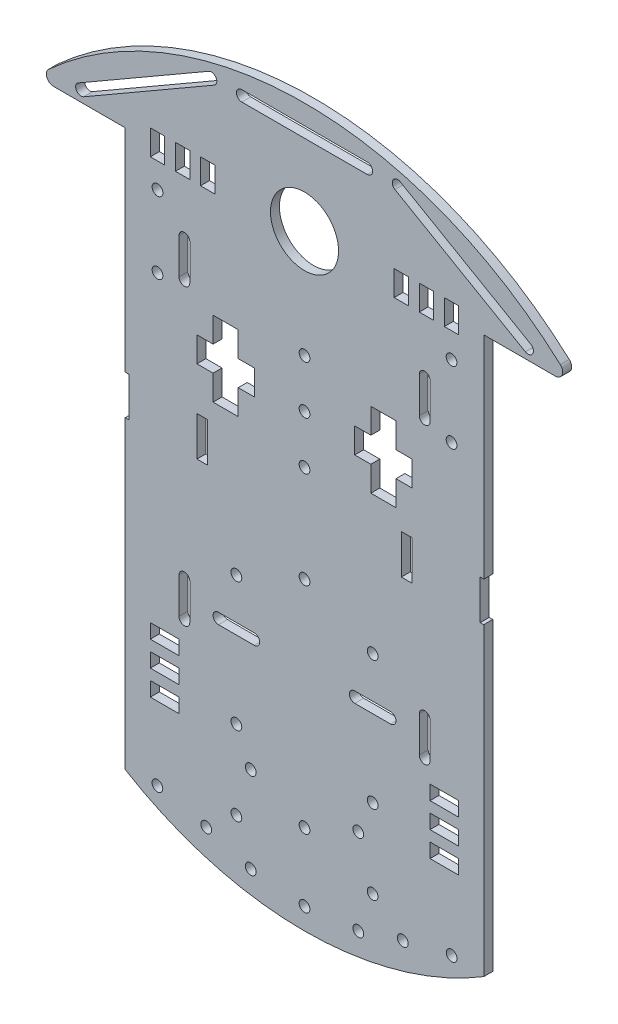
from build123d import *

# Parameters (mm, degrees)
BOSS_EXTRU_1_DEPTH         = 2.5
ESQUISSE2_R                = 9.5
ENL_V_MAT_EXTRU_1_DEPTH    = 3.5
ESQUISSE3_W                = 4
ESQUISSE3_H                = 7
ENL_V_MAT_EXTRU_2_DEPTH    = 3.5
R_P_TITION_LIN_AIRE1_COUNT = 3
R_P_TITION_LIN_AIRE1_PITCH = 7
ENL_V_MAT_EXTRU_3_DEPTH    = 3.5
ESQUISSE5_W                = 3
ESQUISSE5_H                = 11
ENL_V_MAT_EXTRU_4_DEPTH    = 3.5
R_P_TITION_LIN_AIRE2_COUNT = 2
R_P_TITION_LIN_AIRE2_PITCH = 22
ESQUISSE6_R                = 1.5
ENL_V_MAT_EXTRU_5_DEPTH    = 3.5
ESQUISSE7_W                = 8
ESQUISSE7_H                = 4
ENL_V_MAT_EXTRU_6_DEPTH    = 3.5
SYM_TRIE1_COPY_1_SKETCH_W  = 3
SYM_TRIE1_COPY_1_SKETCH_H  = 11
SYM_TRIE1_COPY_1_DEPTH     = 3.5
SYM_TRIE1_COPY_2_SKETCH_W  = 4
SYM_TRIE1_COPY_2_SKETCH_H  = 7
SYM_TRIE1_COPY_2_DEPTH     = 3.5
SYM_TRIE1_COPY_3_SKETCH_W  = 4
SYM_TRIE1_COPY_3_SKETCH_H  = 7
SYM_TRIE1_COPY_3_DEPTH     = 3.5
ESQUISSE8_R                = 1.5
ENL_V_MAT_EXTRU_7_DEPTH    = 10


with BuildPart() as part:
    # Esquisse1 → Boss.-Extru.1 (new body)
    with BuildSketch(Plane.XY):
        with BuildLine():
            Line((100, 155), (119.994239394, 155))
            ThreePointArc((119.994239394, 155), (121.860222821, 156.2802043), (121.337366241, 158.48189415))
            ThreePointArc((121.337366241, 158.48189415), (50, 186), (-21.337366241, 158.48189415))
            ThreePointArc((-21.337366241, 158.48189415), (-21.860222821, 156.2802043), (-19.994239394, 155))
            Line((-19.994239394, 155), (0, 155))
            Line((0, 155), (0, 0))
            ThreePointArc((0, 0), (50, -14), (100, 0))
            Line((100, 0), (100, 155))
        make_face()
    extrude(amount=BOSS_EXTRU_1_DEPTH)

    # Esquisse2 → Enlèv. mat.-Extru.1 (cut, through all)
    with BuildSketch(Plane(origin=(0, 0, 0), x_dir=(-1, 0, 0), z_dir=(0, 0, -1))):
        with Locations((-50, 155)):
            Circle(ESQUISSE2_R)
    extrude(amount=-ENL_V_MAT_EXTRU_1_DEPTH, mode=Mode.SUBTRACT)

    # Esquisse3 → Enlèv. mat.-Extru.2 (cut, through all)
    with BuildSketch(Plane(origin=(0, 0, 0), x_dir=(-1, 0, 0), z_dir=(0, 0, -1))):
        with Locations((-91, 155)):
            Rectangle(ESQUISSE3_W, ESQUISSE3_H)
    enl_v_mat_extru_2 = extrude(amount=-ENL_V_MAT_EXTRU_2_DEPTH, mode=Mode.SUBTRACT)

    # Répétition linéaire1: Enlèv. mat.-Extru.2 ×3
    with Locations(*[(-i * R_P_TITION_LIN_AIRE1_PITCH, 0, 0) for i in range(1, R_P_TITION_LIN_AIRE1_COUNT)]):
        add(enl_v_mat_extru_2, mode=Mode.SUBTRACT)

    # Esquisse4 → Enlèv. mat.-Extru.3 (cut, through all)
    with BuildSketch(Plane(origin=(0, 0, 0), x_dir=(-1, 0, 0), z_dir=(0, 0, -1))):
        Polygon((-75.5, 122), (-68.5, 122), (-68.5, 115), (-64, 115), (-64, 108), (-68.5, 108), (-68.5, 101), (-75.5, 101), (-75.5, 108), (-80, 108), (-80, 115), (-75.5, 115), align=None)
    enl_v_mat_extru_3 = extrude(amount=-ENL_V_MAT_EXTRU_3_DEPTH, mode=Mode.SUBTRACT)

    # Esquisse5 → Enlèv. mat.-Extru.4 (cut, through all)
    with BuildSketch(Plane(origin=(0, 0, 0), x_dir=(-1, 0, 0), z_dir=(0, 0, -1))):
        with Locations((-78.5, 90.5)):
            Rectangle(ESQUISSE5_W, ESQUISSE5_H)
    enl_v_mat_extru_4 = extrude(amount=-ENL_V_MAT_EXTRU_4_DEPTH, mode=Mode.SUBTRACT)

    # Répétition linéaire2: Enlèv. mat.-Extru.4 ×2
    with Locations(*[(i * R_P_TITION_LIN_AIRE2_PITCH, 0, 0) for i in range(1, R_P_TITION_LIN_AIRE2_COUNT)]):
        add(enl_v_mat_extru_4, mode=Mode.SUBTRACT)

    # Esquisse6 → Enlèv. mat.-Extru.5 (cut, through all)
    with BuildSketch(Plane(origin=(0, 0, 0), x_dir=(-1, 0, 0), z_dir=(0, 0, -1))):
        with Locations((-91, 144.5)):
            Circle(ESQUISSE6_R)
        with Locations((-91, 124.5)):
            Circle(ESQUISSE6_R)
        with Locations((-65, 17.5)):
            Circle(ESQUISSE6_R)
        with Locations((-69, 26.5)):
            Circle(ESQUISSE6_R)
        with Locations((-91.030029605, 0.602552335)):
            Circle(ESQUISSE6_R)
        with Locations((-77.401365798, -2.600496654)):
            Circle(ESQUISSE6_R)
        with Locations((-69, 4.5)):
            Circle(ESQUISSE6_R)
        with Locations((-65, -6.5)):
            Circle(ESQUISSE6_R)
        with Locations((-69, 62.5)):
            Circle(ESQUISSE6_R)
        with BuildLine():
            Line((-82, 54.5), (-82, 44.5))
            ThreePointArc((-82, 44.5), (-83.5, 43), (-85, 44.5))
            Line((-85, 44.5), (-85, 54.5))
            ThreePointArc((-85, 54.5), (-83.5, 56), (-82, 54.5))
        make_face()
        with BuildLine():
            Line((-74, 51), (-64, 51))
            ThreePointArc((-64, 51), (-62.5, 49.5), (-64, 48))
            Line((-64, 48), (-74, 48))
            ThreePointArc((-74, 48), (-75.5, 49.5), (-74, 51))
        make_face()
        with BuildLine():
            Line((-82, 136.5), (-82, 126.5))
            ThreePointArc((-82, 126.5), (-83.5, 125), (-85, 126.5))
            Line((-85, 126.5), (-85, 136.5))
            ThreePointArc((-85, 136.5), (-83.5, 138), (-82, 136.5))
        make_face()
        with BuildLine():
            Line((-113.087366241, 159.299038106), (-76.714299282, 180.299038106))
            ThreePointArc((-76.714299282, 180.299038106), (-74.665261177, 179.75), (-75.214299282, 177.700961894))
            Line((-75.214299282, 177.700961894), (-111.587366241, 156.700961894))
            ThreePointArc((-111.587366241, 156.700961894), (-113.636404347, 157.25), (-113.087366241, 159.299038106))
        make_face()
    enl_v_mat_extru_5 = extrude(amount=-ENL_V_MAT_EXTRU_5_DEPTH, mode=Mode.SUBTRACT)

    # Esquisse7 → Enlèv. mat.-Extru.6 (cut, through all)
    with BuildSketch(Plane(origin=(0, 0, 0), x_dir=(-1, 0, 0), z_dir=(0, 0, -1))):
        with Locations((-89, 37)):
            Rectangle(ESQUISSE7_W, ESQUISSE7_H)
        with Locations((-89, 30)):
            Rectangle(ESQUISSE7_W, ESQUISSE7_H)
        with Locations((-89, 23)):
            Rectangle(ESQUISSE7_W, ESQUISSE7_H)
    enl_v_mat_extru_6 = extrude(amount=-ENL_V_MAT_EXTRU_6_DEPTH, mode=Mode.SUBTRACT)

    # Symétrie1: Enlèv. mat.-Extru.2, Enlèv. mat.-Extru.3, Enlèv. mat.-Extru.4, Enlèv. mat.-Extru.5, Enlèv. mat.-Extru.6 across plane
    add(enl_v_mat_extru_2.mirror(Plane(origin=(50, 0, 0), x_dir=(0, 0, 1), z_dir=(1, 0, 0))), mode=Mode.SUBTRACT)
    add(enl_v_mat_extru_3.mirror(Plane(origin=(50, 0, 0), x_dir=(0, 0, 1), z_dir=(1, 0, 0))), mode=Mode.SUBTRACT)
    add(enl_v_mat_extru_4.mirror(Plane(origin=(50, 0, 0), x_dir=(0, 0, 1), z_dir=(1, 0, 0))), mode=Mode.SUBTRACT)
    add(enl_v_mat_extru_5.mirror(Plane(origin=(50, 0, 0), x_dir=(0, 0, 1), z_dir=(1, 0, 0))), mode=Mode.SUBTRACT)
    add(enl_v_mat_extru_6.mirror(Plane(origin=(50, 0, 0), x_dir=(0, 0, 1), z_dir=(1, 0, 0))), mode=Mode.SUBTRACT)

    # Symétrie1 copy 1 sketch → Symétrie1 copy 1 (cut, through all)
    with BuildSketch(Plane(origin=(78, 0, 0), x_dir=(1, 0, 0), z_dir=(0, 0, -1))):
        with Locations((-78.5, -90.5)):
            Rectangle(SYM_TRIE1_COPY_1_SKETCH_W, SYM_TRIE1_COPY_1_SKETCH_H)
    extrude(amount=-SYM_TRIE1_COPY_1_DEPTH, mode=Mode.SUBTRACT)

    # Symétrie1 copy 2 sketch → Symétrie1 copy 2 (cut, through all)
    with BuildSketch(Plane(origin=(107, 0, 0), x_dir=(1, 0, 0), z_dir=(0, 0, -1))):
        with Locations((-91, -155)):
            Rectangle(SYM_TRIE1_COPY_2_SKETCH_W, SYM_TRIE1_COPY_2_SKETCH_H)
    extrude(amount=-SYM_TRIE1_COPY_2_DEPTH, mode=Mode.SUBTRACT)

    # Symétrie1 copy 3 sketch → Symétrie1 copy 3 (cut, through all)
    with BuildSketch(Plane(origin=(114, 0, 0), x_dir=(1, 0, 0), z_dir=(0, 0, -1))):
        with Locations((-91, -155)):
            Rectangle(SYM_TRIE1_COPY_3_SKETCH_W, SYM_TRIE1_COPY_3_SKETCH_H)
    extrude(amount=-SYM_TRIE1_COPY_3_DEPTH, mode=Mode.SUBTRACT)

    # Esquisse8 → Enlèv. mat.-Extru.7 (cut)
    with BuildSketch(Plane(origin=(0, 0, 0), x_dir=(-1, 0, 0), z_dir=(0, 0, -1))):
        with Locations((-50, 111.5)):
            Circle(ESQUISSE8_R)
        with Locations((-50, 125)):
            Circle(ESQUISSE8_R)
        with Locations((-50, 98)):
            Circle(ESQUISSE8_R)
        with Locations((-50, 71)):
            Circle(ESQUISSE8_R)
        with Locations((-50, -8)):
            Circle(ESQUISSE8_R)
        with Locations((-50, 11)):
            Circle(ESQUISSE8_R)
        with BuildLine():
            Line((-67.5, 180.480620573), (-32.5, 180.480620573))
            ThreePointArc((-32.5, 180.480620573), (-31, 178.980620573), (-32.5, 177.480620573))
            Line((-32.5, 177.480620573), (-67.5, 177.480620573))
            ThreePointArc((-67.5, 177.480620573), (-69, 178.980620573), (-67.5, 180.480620573))
        make_face()
    extrude(amount=-ENL_V_MAT_EXTRU_7_DEPTH, mode=Mode.SUBTRACT)


solid = part.part
